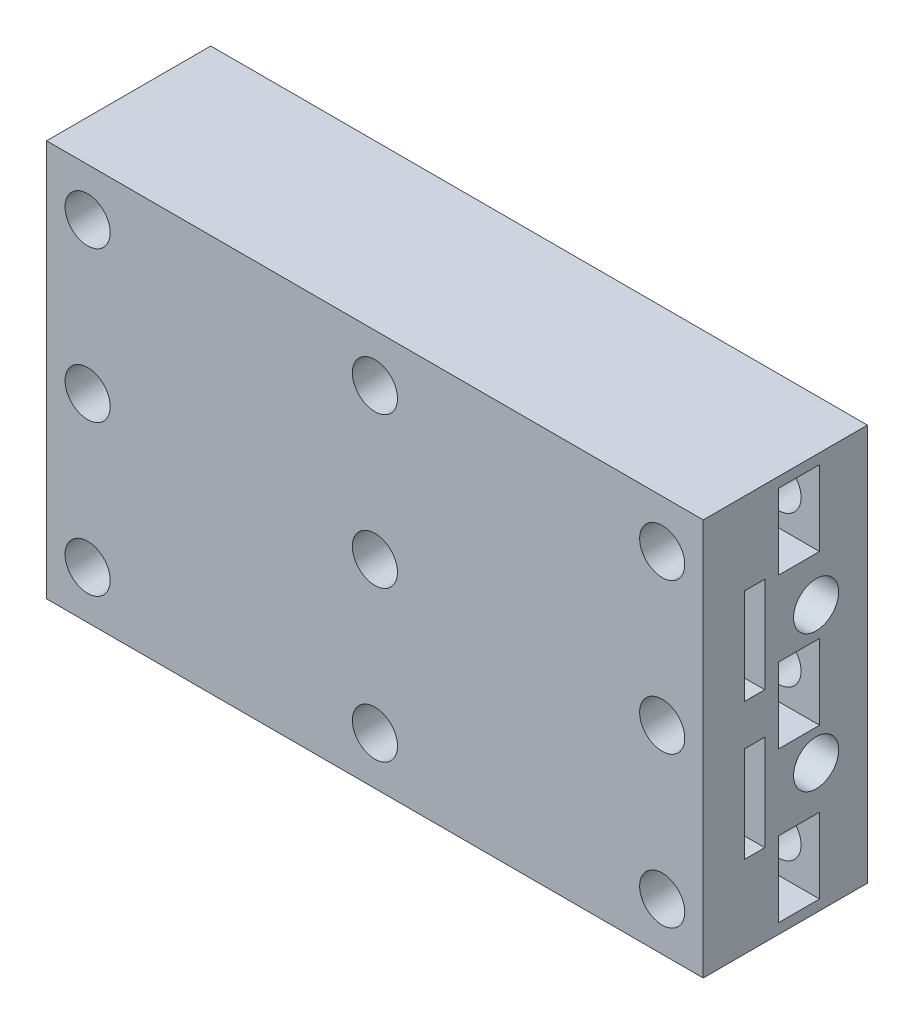
from build123d import *

# Parameters (mm, degrees)
ESBO_O1_W                = 48
ESBO_O1_H                = 29
ESBO_O1_R                = 1.65
RESSALTO_EXTRUS_O1_DEPTH = 12
CORTE_EXTRUS_O3_START    = 1.5
ESBO_O2_R                = 0.6
CORTE_EXTRUS_O3_DEPTH    = 7
ESBO_O3_R                = 1.65
CORTE_EXTRUS_O4_DEPTH    = 16
CORTE_EXTRUS_O5_DEPTH    = 2
ESBO_O5_W                = 3
ESBO_O5_H                = 5.5
CORTE_EXTRUS_O6_DEPTH    = 7
ESBO_O6_R                = 1.65
CORTE_EXTRUS_O7_DEPTH    = 13
ESBO_O7_R                = 3.4
CORTE_EXTRUS_O9_DEPTH    = 3


with BuildPart() as part:
    # Esboço1 → Ressalto-extrusão1 (new body)
    with BuildSketch(Plane.XY):
        Rectangle(ESBO_O1_W, ESBO_O1_H)
        with Locations((-21, 11)):
            Circle(ESBO_O1_R, mode=Mode.SUBTRACT)
        with Locations((-21, -11)):
            Circle(ESBO_O1_R, mode=Mode.SUBTRACT)
        with Locations((21, -11)):
            Circle(ESBO_O1_R, mode=Mode.SUBTRACT)
        with Locations((21, 11)):
            Circle(ESBO_O1_R, mode=Mode.SUBTRACT)
    extrude(amount=RESSALTO_EXTRUS_O1_DEPTH)

    # Esboço2 → Corte-extrusão3 (cut)
    with BuildSketch(Plane(origin=(0, 0, 0), x_dir=(1, 0, 0), z_dir=(0, 1, 0)).offset(CORTE_EXTRUS_O3_START)):
        with Locations((-23, 0)):
            Circle(ESBO_O2_R)
        with Locations((-21, 0)):
            Circle(ESBO_O2_R)
        with Locations((-19, 0)):
            Circle(ESBO_O2_R)
        with Locations((19, 0)):
            Circle(ESBO_O2_R)
        with Locations((21, 0)):
            Circle(ESBO_O2_R)
        with Locations((23, 0)):
            Circle(ESBO_O2_R)
        with BuildLine():
            Line((-24, -9), (-8, -9))
            ThreePointArc((-8, -9), (-4.818019485, -7.681980515), (-3.5, -4.5))
            Line((-3.5, -4.5), (-3.5, 0))
            Line((-3.5, 0), (-18, 0))
            Line((-18, 0), (-18, -7.5))
            Line((-18, -7.5), (-24, -7.5))
            Line((-24, -7.5), (-24, -9))
        make_face()
        with BuildLine():
            Line((24, -7.5), (24, -9))
            Line((24, -9), (8, -9))
            ThreePointArc((8, -9), (4.818019485, -7.681980515), (3.5, -4.5))
            Line((3.5, -4.5), (3.5, 0))
            Line((3.5, 0), (18, 0))
            Line((18, 0), (18, -7.5))
            Line((18, -7.5), (24, -7.5))
        make_face()
    corte_extrus_o3 = extrude(amount=CORTE_EXTRUS_O3_DEPTH, mode=Mode.SUBTRACT)

    # Espelhar1: Corte-extrusão3 across plane
    add(corte_extrus_o3.mirror(Plane.ZX), mode=Mode.SUBTRACT)

    # Esboço3 → Corte-extrusão4 (cut)
    with BuildSketch(Plane(origin=(24, 0, 0), x_dir=(0, 0, -1), z_dir=(1, 0, 0))):
        with Locations((-3.75, 5)):
            Circle(ESBO_O3_R)
        with Locations((-3.75, -5)):
            Circle(ESBO_O3_R)
    corte_extrus_o4 = extrude(amount=-CORTE_EXTRUS_O4_DEPTH, mode=Mode.SUBTRACT)

    # Esboço4 → Corte-extrusão5 (cut)
    with BuildSketch(Plane.ZY.offset(-18)):
        Polygon((6.925426481, 5), (5.33771324, 7.75), (2.16228676, 7.75), (0.574573519, 5), (2.16228676, 2.25), (5.33771324, 2.25), align=None)
        Polygon((6.925426481, -5), (5.33771324, -2.25), (2.16228676, -2.25), (0.574573519, -5), (2.16228676, -7.75), (5.33771324, -7.75), align=None)
    corte_extrus_o5 = extrude(amount=-CORTE_EXTRUS_O5_DEPTH, mode=Mode.SUBTRACT)

    # Esboço5 → Corte-extrusão6 (cut)
    with BuildSketch(Plane(origin=(24, 0, 0), x_dir=(0, 0, -1), z_dir=(1, 0, 0))):
        with Locations((-5, 0)):
            Rectangle(ESBO_O5_W, ESBO_O5_H)
        with Locations((-5, 11)):
            Rectangle(ESBO_O5_W, ESBO_O5_H)
        with Locations((-5, -11)):
            Rectangle(ESBO_O5_W, ESBO_O5_H)
    corte_extrus_o6 = extrude(amount=-CORTE_EXTRUS_O6_DEPTH, mode=Mode.SUBTRACT)

    # Esboço6 → Corte-extrusão7 (cut, through all)
    with BuildSketch(Plane(origin=(0, 0, 0), x_dir=(-1, 0, 0), z_dir=(0, 0, -1))):
        with Locations((-21, 0)):
            Circle(ESBO_O6_R)
        with Locations((21, 0)):
            Circle(ESBO_O6_R)
        Circle(ESBO_O6_R)
        with Locations((0, 11)):
            Circle(ESBO_O6_R)
        with Locations((0, -11)):
            Circle(ESBO_O6_R)
    extrude(amount=-CORTE_EXTRUS_O7_DEPTH, mode=Mode.SUBTRACT)

    # Espelhar2: Corte-extrusão4, Corte-extrusão5, Corte-extrusão6 across plane
    add(corte_extrus_o4.mirror(Plane(origin=(0, 0, 0), x_dir=(0, 0, 1), z_dir=(1, 0, 0))), mode=Mode.SUBTRACT)
    add(corte_extrus_o5.mirror(Plane(origin=(0, 0, 0), x_dir=(0, 0, 1), z_dir=(1, 0, 0))), mode=Mode.SUBTRACT)
    add(corte_extrus_o6.mirror(Plane(origin=(0, 0, 0), x_dir=(0, 0, 1), z_dir=(1, 0, 0))), mode=Mode.SUBTRACT)

    # Esboço7 → Corte-extrusão9 (cut)
    with BuildSketch(Plane(origin=(0, 0, 0), x_dir=(-1, 0, 0), z_dir=(0, 0, -1))):
        with Locations((0, 11)):
            Circle(ESBO_O7_R)
        Circle(ESBO_O7_R)
        with Locations((0, -11)):
            Circle(ESBO_O7_R)
    extrude(amount=-CORTE_EXTRUS_O9_DEPTH, mode=Mode.SUBTRACT)


solid = part.part
